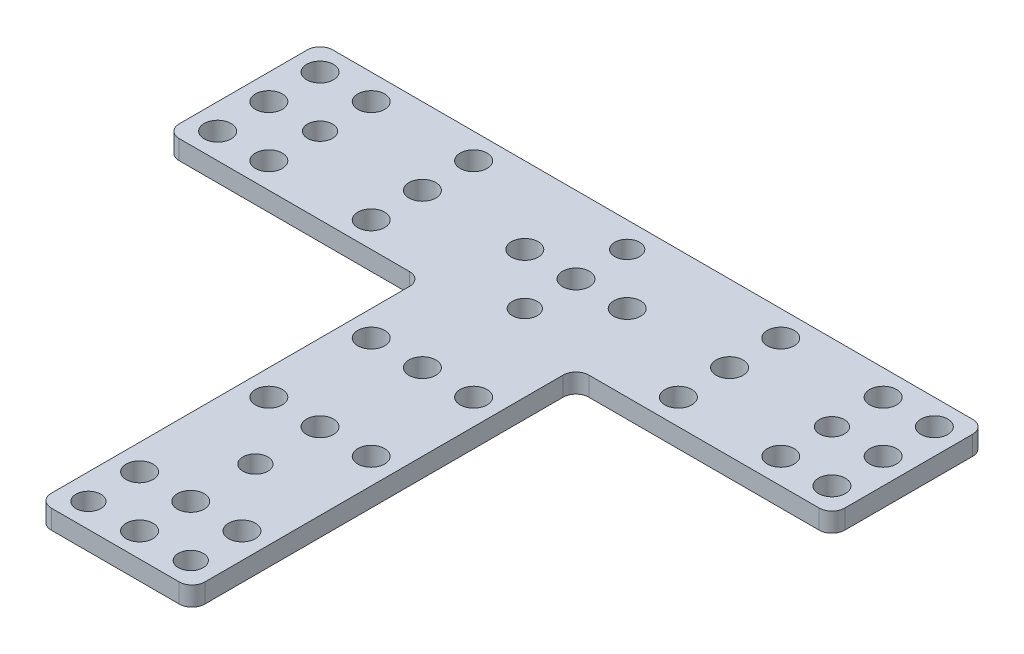
from build123d import *

# Parameters (mm, degrees)
BOSS_EXTRUDE1_DEPTH = 3
SKETCH2_R           = 2.1
SKETCH2_R_2         = 1.95
CUT_EXTRUDE1_DEPTH  = 4
FILLET1_R           = 2


with BuildPart() as part:
    # Sketch1 → Boss-Extrude1 (new body)
    with BuildSketch(Plane(origin=(0, 0, 0), x_dir=(1, 0, 0), z_dir=(0, 1, 0))):
        Polygon((12, 0), (52, 0), (52, 24), (-52, 24), (-52, 0), (-12, 0), (-12, -60), (12, -60), align=None)
    extrude(amount=BOSS_EXTRUDE1_DEPTH)

    # Sketch2 → Cut-Extrude1 (cut, through all)
    with BuildSketch(Plane(origin=(0, 3, 0), x_dir=(1, 0, 0), z_dir=(0, 1, 0))):
        with Locations((0, 12)):
            Circle(SKETCH2_R)
        with Locations((-8, 12)):
            Circle(SKETCH2_R)
        with Locations((0, 20)):
            Circle(SKETCH2_R_2)
        with Locations((-48, 12)):
            Circle(SKETCH2_R)
        with Locations((-48, 20)):
            Circle(SKETCH2_R)
        with Locations((-40, 12)):
            Circle(SKETCH2_R_2)
        with Locations((-40, 20)):
            Circle(SKETCH2_R)
        with Locations((-24, 12)):
            Circle(SKETCH2_R)
        with Locations((-24, 20)):
            Circle(SKETCH2_R)
        with Locations((0, -12)):
            Circle(SKETCH2_R)
        with Locations((0, -28)):
            Circle(SKETCH2_R)
        with Locations((0, -38.1)):
            Circle(SKETCH2_R_2)
        with Locations((0, -48.2)):
            Circle(SKETCH2_R)
        with Locations((0, -56.2)):
            Circle(SKETCH2_R)
        with Locations((-8, -56.2)):
            Circle(SKETCH2_R_2)
        with Locations((-8, -48.2)):
            Circle(SKETCH2_R)
        with Locations((-8, -28)):
            Circle(SKETCH2_R)
        with Locations((-8, -12)):
            Circle(SKETCH2_R)
        with Locations((0, 4)):
            Circle(SKETCH2_R_2)
        with Locations((-24, 4)):
            Circle(SKETCH2_R)
        with Locations((-40, 4)):
            Circle(SKETCH2_R)
        with Locations((-48, 4)):
            Circle(SKETCH2_R)
        with Locations((8, -56.2)):
            Circle(SKETCH2_R_2)
        with Locations((8, -48.2)):
            Circle(SKETCH2_R)
        with Locations((8, -28)):
            Circle(SKETCH2_R)
        with Locations((8, -12)):
            Circle(SKETCH2_R)
        with Locations((8, 12)):
            Circle(SKETCH2_R)
        with Locations((24, 4)):
            Circle(SKETCH2_R)
        with Locations((24, 20)):
            Circle(SKETCH2_R)
        with Locations((24, 12)):
            Circle(SKETCH2_R)
        with Locations((40, 20)):
            Circle(SKETCH2_R)
        with Locations((40, 12)):
            Circle(SKETCH2_R_2)
        with Locations((48, 12)):
            Circle(SKETCH2_R)
        with Locations((40, 4)):
            Circle(SKETCH2_R)
        with Locations((48, 4)):
            Circle(SKETCH2_R)
        with Locations((48, 20)):
            Circle(SKETCH2_R)
    extrude(amount=-CUT_EXTRUDE1_DEPTH, mode=Mode.SUBTRACT)

    # Fillet1
    fillet1_edges = [part.edges().sort_by_distance(p)[0] for p in [
        (-52, 1.5, -24),
        (52, 1.5, -24),
        (52, 1.5, 0),
        (12, 1.5, 0),
        (12, 1.5, 60),
        (-12, 1.5, 60),
        (-12, 1.5, 0),
        (-52, 1.5, 0),
    ]]
    fillet(fillet1_edges, radius=FILLET1_R)


solid = part.part
